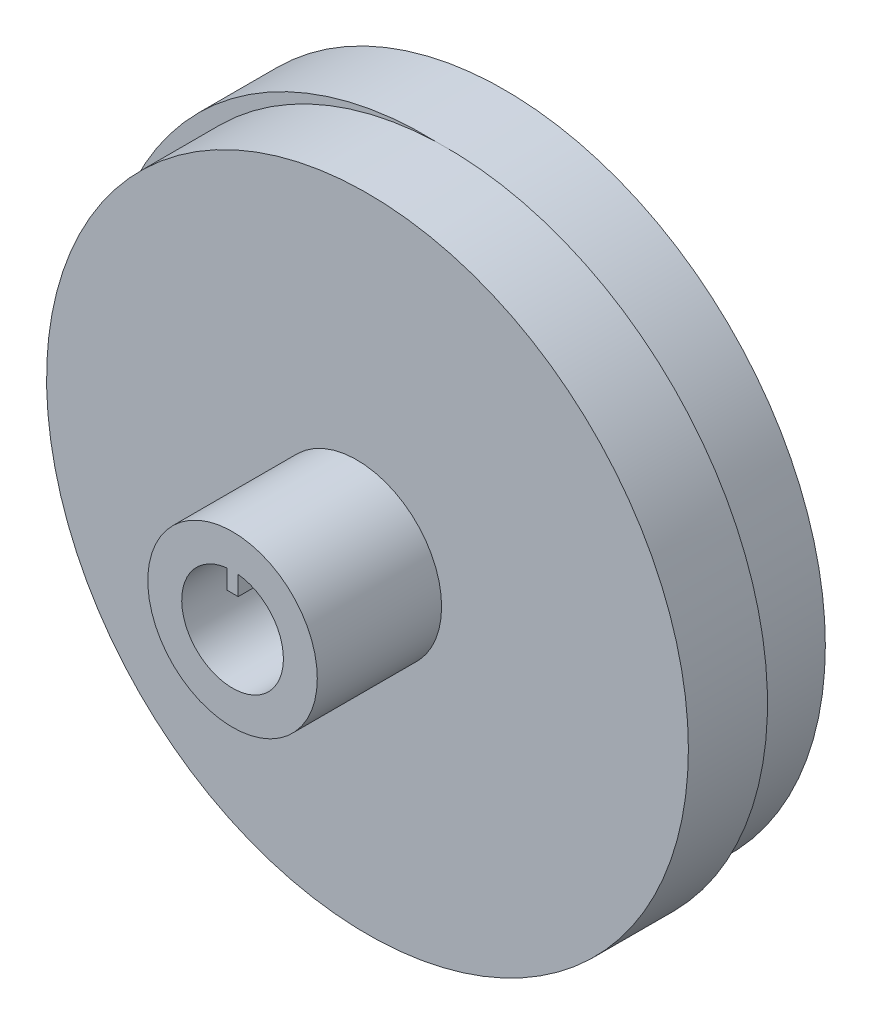
from build123d import *

# Parameters (mm, degrees)
SKETCH1_R           = 28.4
BOSS_EXTRUDE1_DEPTH = 7
SKETCH2_R           = 28.4
BOSS_EXTRUDE3_DEPTH = 7
SKETCH4_R           = 7.5
BOSS_EXTRUDE4_DEPTH = 11
CUT_EXTRUDE1_DEPTH  = 10


with BuildPart() as part:
    # Sketch1 → Boss-Extrude1 (new body)
    with BuildSketch(Plane.XY):
        Circle(SKETCH1_R)
    extrude(amount=BOSS_EXTRUDE1_DEPTH)

    # Sketch2 → Boss-Extrude3 (add)
    with BuildSketch(Plane.XY.offset(7)):
        with Locations((1.88, 0)):
            Circle(SKETCH2_R)
    extrude(amount=BOSS_EXTRUDE3_DEPTH)

    # Sketch4 → Boss-Extrude4 (add)
    with BuildSketch(Plane.XY.offset(14)):
        with Locations((0.94, 0)):
            Circle(SKETCH4_R)
    extrude(amount=BOSS_EXTRUDE4_DEPTH)

    # Sketch6 → Cut-Extrude1 (cut)
    with BuildSketch(Plane.XY.offset(25)):
        with BuildLine():
            Line((0.44, 2.770056), (1.44, 2.770056))
            Line((1.44, 2.770056), (1.44, 4.472135955))
            ThreePointArc((1.44, 4.472135955), (0.94, -4.5), (0.44, 4.472135955))
            Line((0.44, 4.472135955), (0.44, 2.770056))
        make_face()
    extrude(amount=-CUT_EXTRUDE1_DEPTH, mode=Mode.SUBTRACT)


solid = part.part
